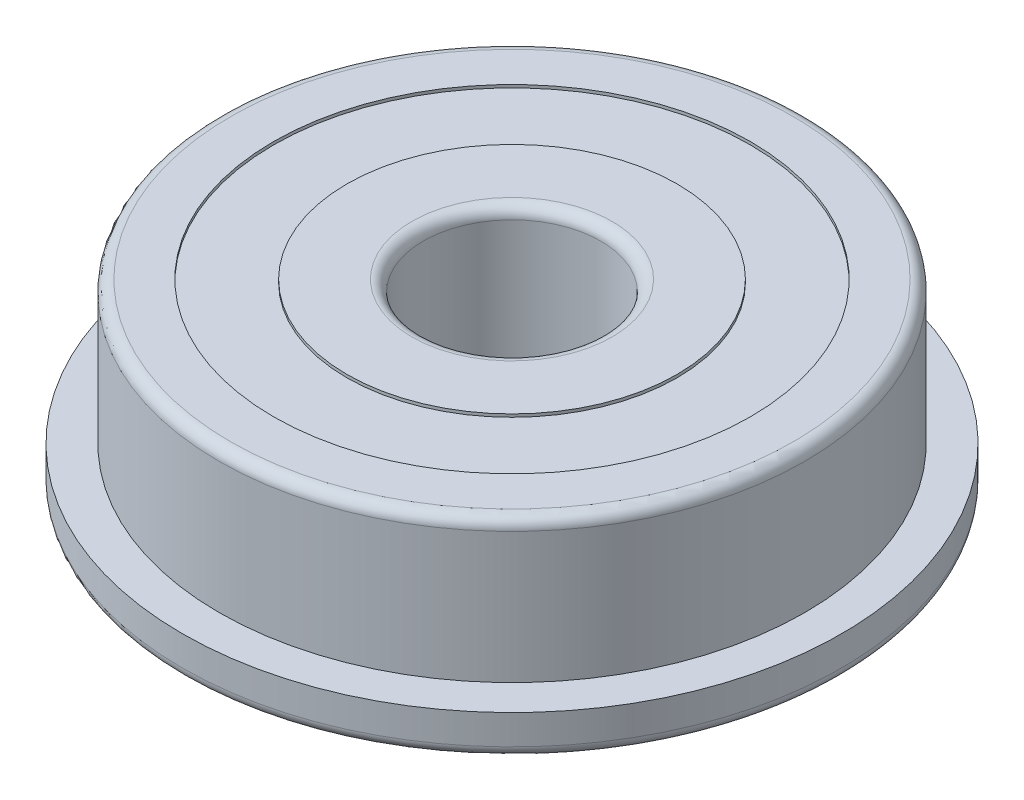
from build123d import *

# Parameters (mm, degrees)
SKETCH1_R           = 8.985
BOSS_EXTRUDE1_DEPTH = 1.12
SKETCH2_R           = 7.985
BOSS_EXTRUDE2_DEPTH = 3.88
SKETCH3_R           = 2.42
CUT_EXTRUDE1_DEPTH  = 6
SKETCH4_R           = 6.5
SKETCH4_R_2         = 4.5
CUT_EXTRUDE2_DEPTH  = 0.08
SKETCH5_R           = 6.5
SKETCH5_R_2         = 4.5
CUT_EXTRUDE3_DEPTH  = 0.08
FILLET1_R           = 0.31


with BuildPart() as part:
    # Sketch1 → Boss-Extrude1 (new body)
    with BuildSketch(Plane(origin=(0, 0, 0), x_dir=(1, 0, 0), z_dir=(0, 1, 0))):
        Circle(SKETCH1_R)
    extrude(amount=BOSS_EXTRUDE1_DEPTH)

    # Sketch2 → Boss-Extrude2 (add)
    with BuildSketch(Plane(origin=(0, 1.12, 0), x_dir=(1, 0, 0), z_dir=(0, 1, 0))):
        Circle(SKETCH2_R)
    extrude(amount=BOSS_EXTRUDE2_DEPTH)

    # Sketch3 → Cut-Extrude1 (cut, through all)
    with BuildSketch(Plane(origin=(0, 5, 0), x_dir=(1, 0, 0), z_dir=(0, 1, 0))):
        Circle(SKETCH3_R)
    extrude(amount=-CUT_EXTRUDE1_DEPTH, mode=Mode.SUBTRACT)

    # Sketch4 → Cut-Extrude2 (cut)
    with BuildSketch(Plane.XZ):
        Circle(SKETCH4_R)
        Circle(SKETCH4_R_2, mode=Mode.SUBTRACT)
    extrude(amount=-CUT_EXTRUDE2_DEPTH, mode=Mode.SUBTRACT)

    # Sketch5 → Cut-Extrude3 (cut)
    with BuildSketch(Plane(origin=(0, 5, 0), x_dir=(1, 0, 0), z_dir=(0, 1, 0))):
        Circle(SKETCH5_R)
        Circle(SKETCH5_R_2, mode=Mode.SUBTRACT)
    extrude(amount=-CUT_EXTRUDE3_DEPTH, mode=Mode.SUBTRACT)

    # Fillet1
    fillet1_edges = [part.edges().sort_by_distance(p)[0] for p in [
        (-2.42, 0, 0),
        (-2.42, 5, 0),
        (-8.985, 0, 0),
        (-7.985, 5, 0),
    ]]
    fillet(fillet1_edges, radius=FILLET1_R)


solid = part.part
